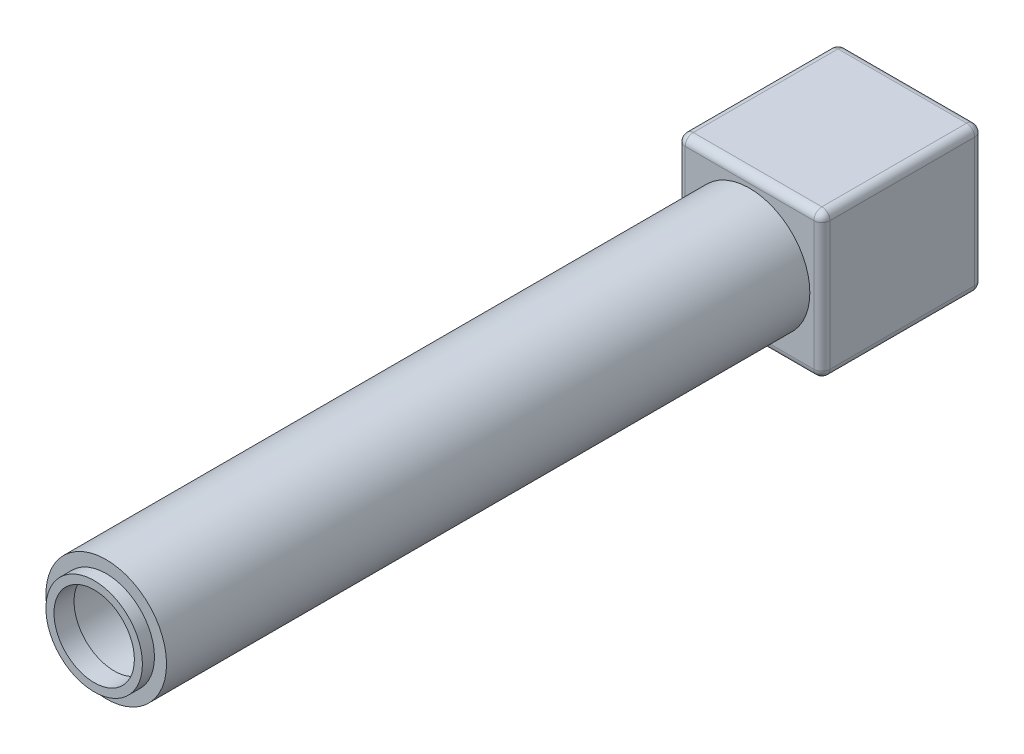
from build123d import *

# Parameters (mm, degrees)
SKETCH_1_R            = 7.5
EXTRUDE_1_DEPTH       = 80
SHELL_3_T             = -1.5
SKETCH_18_W           = 18
SKETCH_18_H           = 18
EXTRUDE_10_DEPTH      = 20
SKETCH_19_W           = 15
SKETCH_19_H           = 15
CUT_EXTRUDE_5_DEPTH   = 17
SKETCH_22_R           = 7.5
CUT_EXTRUDE_7_DEPTH   = 1.5
SKETCH_4_R            = 6
SKETCH_4_R_2          = 5
EXTRUDE_11_DEPTH      = 1.5
EXTRUDE_11_DEPTH_BACK = 1
SKETCH_23_R           = 6
CUT_EXTRUDE_8_DEPTH   = 3
FILLET_2_R            = 1


with BuildPart() as part:
    # 草图1 → 凸台-拉伸1 (new body)
    with BuildSketch(Plane.XY):
        Circle(SKETCH_1_R)
    extrude(amount=EXTRUDE_1_DEPTH)

    # 抽壳3
    shell_3_openings = [part.faces().sort_by_distance(p)[0] for p in [
        (0, 0, 80),
        (0, 0, 0),
    ]]
    offset(amount=SHELL_3_T, openings=shell_3_openings, kind=Kind.INTERSECTION)

    # 草图18 → 凸台-拉伸10 (add)
    with BuildSketch(Plane.XY):
        Rectangle(SKETCH_18_W, SKETCH_18_H)
    extrude(amount=-EXTRUDE_10_DEPTH)

    # 草图19 → 切除-拉伸5 (cut)
    with BuildSketch(Plane.XY.offset(-1.5)):
        Rectangle(SKETCH_19_W, SKETCH_19_H)
    extrude(amount=-CUT_EXTRUDE_5_DEPTH, mode=Mode.SUBTRACT)

    # 草图22 → 切除-拉伸7 (cut)
    with BuildSketch(Plane(origin=(0, -9, 0), x_dir=(-1, 0, 0), z_dir=(0, -1, 0))):
        with Locations(Location((0, 10, 0), (0, 0, 90))):
            Circle(SKETCH_22_R)
    extrude(amount=-CUT_EXTRUDE_7_DEPTH, mode=Mode.SUBTRACT)

    # 草图23 → 切除-拉伸8 (cut)
    with BuildSketch(Plane(origin=(0, 0, -1.5), x_dir=(-1, 0, 0), z_dir=(0, 0, -1))):
        with Locations(Location((0, 0, 0), (0, 0, 180))):
            Circle(SKETCH_23_R)
    extrude(amount=-CUT_EXTRUDE_8_DEPTH, mode=Mode.SUBTRACT)

    # 圆角2
    fillet_2_edges = [part.edges().sort_by_distance(p)[0] for p in [
        (9, 0, -20),
        (9, 9, -10),
        (0, -9, -20),
        (9, -9, -10),
        (-9, 0, -20),
        (-9, -9, -10),
        (0, 9, -20),
        (-9, 9, -10),
        (9, 0, 0),
        (0, 9, 0),
        (-9, 0, 0),
        (0, -9, 0),
    ]]
    fillet(fillet_2_edges, radius=FILLET_2_R)


with BuildPart() as body_2:
    # 草图4 → 凸台-拉伸11 (new, two sides)
    with BuildSketch(Plane.XY.offset(80)) as extrude_11_sk:
        Circle(SKETCH_4_R)
        Circle(SKETCH_4_R_2, mode=Mode.SUBTRACT)
    extrude(amount=EXTRUDE_11_DEPTH)
    extrude(extrude_11_sk.sketch, amount=-EXTRUDE_11_DEPTH_BACK)


solid = Compound([part.part, body_2.part])
